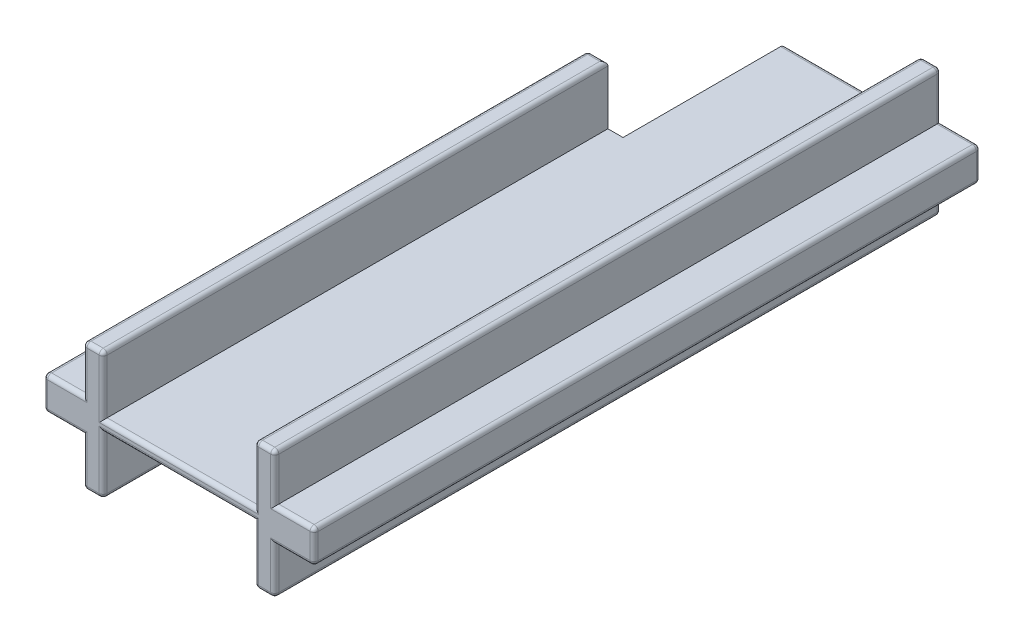
from build123d import *

# Parameters (mm, degrees)
AUFSATZ_LINEAR_AUSTRAGEN1_DEPTH = 25
SKIZZE2_W                       = 6
SKIZZE2_H                       = 1.65
AUFSATZ_LINEAR_AUSTRAGEN2_DEPTH = 8
SKIZZE3_W                       = 7.5
SKIZZE3_H                       = 0.55
SCHNITT_LINEAR_AUSTRAGEN1_DEPTH = 34
AUFSATZ_LINEAR_AUSTRAGEN3_DEPTH = 8
VERRUNDUNG1_R                   = 0.2


with BuildPart() as part:
    # Skizze1 → Aufsatz-Linear austragen1 (new body)
    with BuildSketch(Plane.XY):
        Polygon((-4.75, 0.825), (-6.7, 0.825), (-6.7, -0.825), (-4.75, -0.825), (-4.75, -3.165), (-3.75, -3.165), (-3.75, -0.825), (3.75, -0.825), (3.75, -3.165), (4.75, -3.165), (4.75, -0.825), (6.7, -0.825), (6.7, 0.825), (4.75, 0.825), (4.75, 3.165), (3.75, 3.165), (3.75, 0.825), (-3.75, 0.825), (-3.75, 3.165), (-4.75, 3.165), align=None)
    extrude(amount=AUFSATZ_LINEAR_AUSTRAGEN1_DEPTH)

    # Skizze2 → Aufsatz-Linear austragen2 (add)
    with BuildSketch(Plane(origin=(0, 0, 0), x_dir=(-1, 0, 0), z_dir=(0, 0, -1))):
        Rectangle(SKIZZE2_W, SKIZZE2_H)
    extrude(amount=AUFSATZ_LINEAR_AUSTRAGEN2_DEPTH)

    # Skizze3 → Schnitt-Linear austragen1 (cut, through all)
    with BuildSketch(Plane.XY.offset(25)):
        with Locations((0, -0.55)):
            Rectangle(SKIZZE3_W, SKIZZE3_H)
        with Locations((0, 0.55)):
            Rectangle(SKIZZE3_W, SKIZZE3_H)
    extrude(amount=-SCHNITT_LINEAR_AUSTRAGEN1_DEPTH, mode=Mode.SUBTRACT)

    # Skizze4 → Aufsatz-Linear austragen3 (add)
    with BuildSketch(Plane(origin=(0, 0, 0), x_dir=(-1, 0, 0), z_dir=(0, 0, -1))):
        Polygon((-3.75, -3.165), (-4.75, -3.165), (-4.75, -0.825), (-6.7, -0.825), (-6.7, 0.825), (-4.75, 0.825), (-4.75, 3.165), (-3.75, 3.165), (-3.75, 0.275), (-3, 0.275), (-3, -0.275), (-3.75, -0.275), align=None)
    extrude(amount=AUFSATZ_LINEAR_AUSTRAGEN3_DEPTH)

    # Verrundung1
    verrundung1_edges = [part.edges().sort_by_distance(p)[0] for p in [
        (4.25, -3.165, -8),
        (3.75, -1.72, -8),
        (3.75, 1.72, -8),
        (4.25, 3.165, -8),
        (4.75, 1.995, -8),
        (5.725, 0.825, -8),
        (6.7, 0, -8),
        (5.725, -0.825, -8),
        (4.75, -1.995, -8),
        (-4.75, -1.995, 25),
        (-4.25, -3.165, 25),
        (-5.725, 0.825, 0),
        (-4.75, 1.995, 0),
        (-4.25, 3.165, 0),
        (-3.75, -1.72, 25),
        (-4.25, -3.165, 0),
        (-4.75, -1.995, 0),
        (-5.725, -0.825, 0),
        (-6.7, 0, 0),
        (3.75, -1.72, 25),
        (4.25, -3.165, 25),
        (-6.7, 0.825, 12.5),
        (-4.75, 3.165, 12.5),
        (-3.75, 3.165, 12.5),
        (3.75, 3.165, 8.5),
        (4.75, 3.165, 8.5),
        (6.7, 0.825, 8.5),
        (6.7, -0.825, 8.5),
        (4.75, -3.165, 8.5),
        (3.75, -3.165, 8.5),
        (-3.75, -3.165, 12.5),
        (-4.75, -3.165, 12.5),
        (-6.7, -0.825, 12.5),
        (4.75, -1.995, 25),
        (5.725, -0.825, 25),
        (6.7, 0, 25),
        (5.725, 0.825, 25),
        (-6.7, 0, 25),
        (4.75, 1.995, 25),
        (4.25, 3.165, 25),
        (3.75, 1.72, 25),
        (-3.75, 1.72, 25),
        (-3, 0, -8),
        (0.375, 0.275, -8),
        (0.375, -0.275, -8),
        (-4.25, 3.165, 25),
        (-4.75, 1.995, 25),
        (-5.725, 0.825, 25),
        (0, -0.275, 25),
        (-5.725, -0.825, 25),
        (0, 0.275, 25),
    ]]
    fillet(verrundung1_edges, radius=VERRUNDUNG1_R)


solid = part.part
